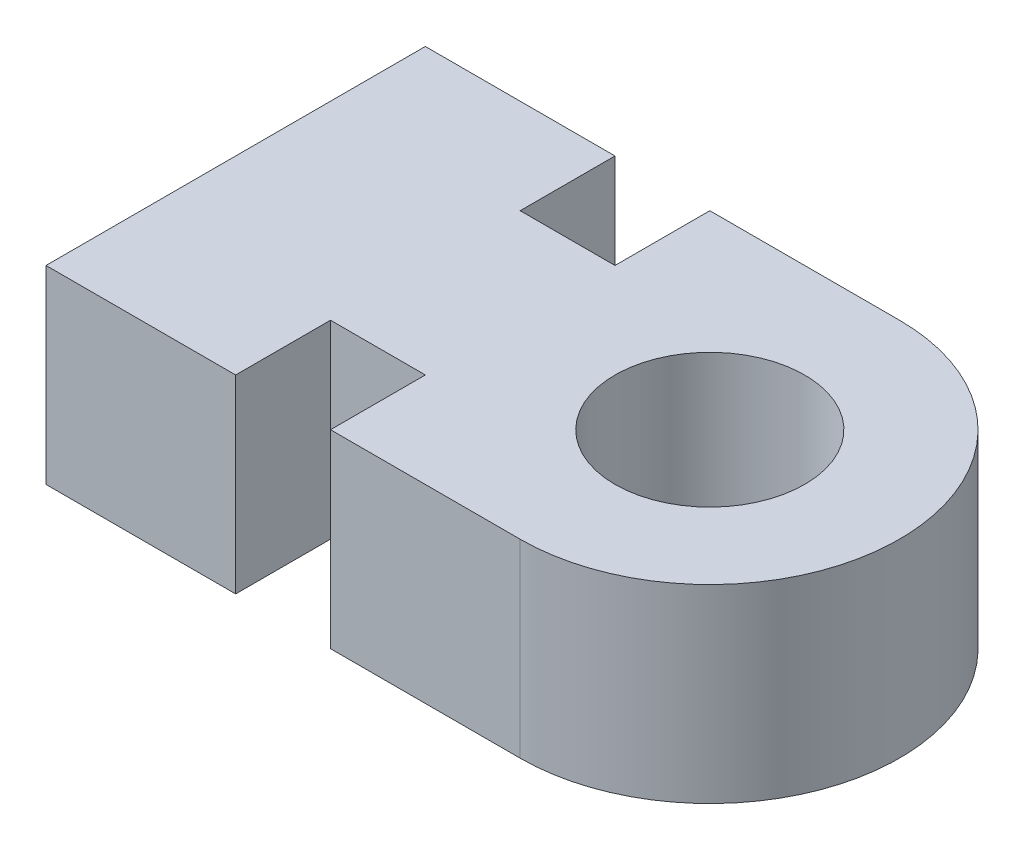
from build123d import *

# Parameters (mm, degrees)
SKETCH_1_R      = 5
EXTRUDE_1_DEPTH = 10
SCALE_1_SCALE   = 0.2


with BuildPart() as part:
    # 草圖1 → 填料-伸長1 (new body)
    with BuildSketch(Plane(origin=(0, 0, 0), x_dir=(1, 0, 0), z_dir=(0, 1, 0))):
        with BuildLine():
            ThreePointArc((0, -10), (10, 0), (0, 10))
            Line((0, 10), (-10, 10))
            Line((-10, 10), (-10, 5))
            Line((-10, 5), (-15, 5))
            Line((-15, 5), (-15, 10))
            Line((-15, 10), (-25, 10))
            Line((-25, 10), (-25, -10))
            Line((-25, -10), (-15, -10))
            Line((-15, -10), (-15, -5))
            Line((-15, -5), (-10, -5))
            Line((-10, -5), (-10, -10))
            Line((-10, -10), (0, -10))
        make_face()
        Circle(SKETCH_1_R, mode=Mode.SUBTRACT)
    extrude(amount=EXTRUDE_1_DEPTH)


with BuildPart() as part_1:
    # 縮放比例1: scaled about (-9.381191691, 5, 0)
    add(part.part.scale(SCALE_1_SCALE).moved(Location((-7.504953353, 4, 0))))


solid = part_1.part
